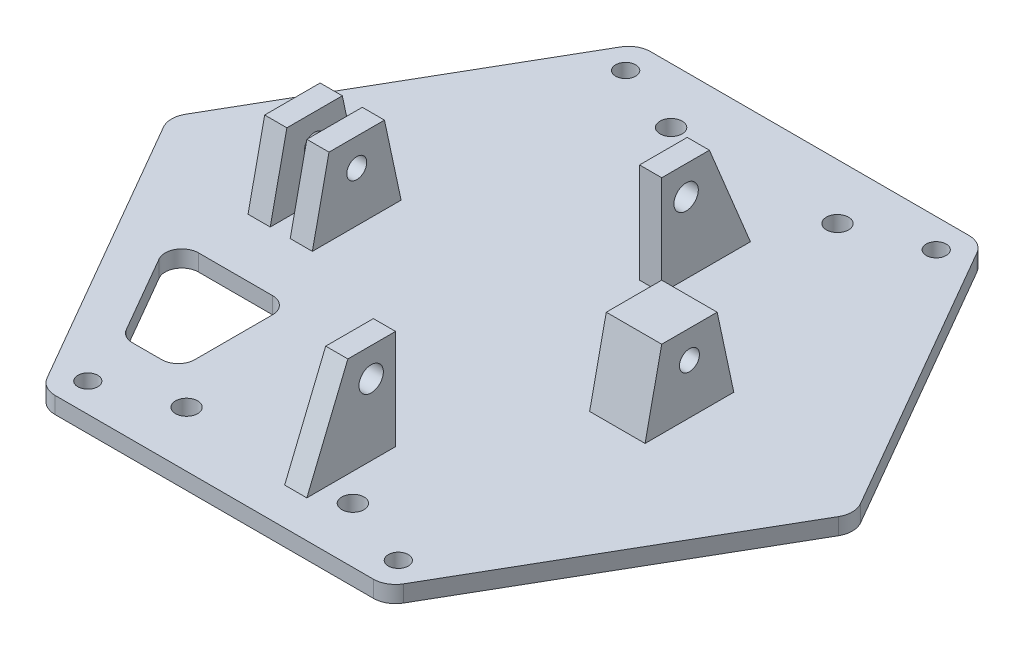
from build123d import *

# Parameters (mm, degrees)
EXTRUDE_1_DEPTH     = 1.5
SKETCH_3_R          = 0.9
EXTRUDE_2_DEPTH     = 2
SKETCH_4_R          = 0.9
EXTRUDE_3_DEPTH     = 2
SKETCH_5_R          = 1.1
EXTRUDE_4_DEPTH     = 2
FILLET_1_R          = 2
SKETCH_6_R          = 0.9
CUT_EXTRUDE_1_DEPTH = 10
SKETCH_7_R          = 1
CUT_EXTRUDE_2_DEPTH = 10
SKETCH_8_R          = 0.9
EXTRUDE_5_DEPTH     = 3
CUT_EXTRUDE_3_DEPTH = 3


with BuildPart() as part:
    # 草图1 → 凸台-拉伸1 (new body)
    with BuildSketch(Plane(origin=(0, 0, 0), x_dir=(1, 0, 0), z_dir=(0, 1, 0))):
        Polygon((15.5, 26.846787517), (-15.5, 26.846787517), (-31, 0), (-15.5, -26.846787517), (15.5, -26.846787517), (31, 0), align=None)
    extrude(amount=EXTRUDE_1_DEPTH)

    # 草图3 → 凸台-拉伸2 (add)
    with BuildSketch(Plane(origin=(16, 0, 0), x_dir=(0, 0, -1), z_dir=(1, 0, 0))):
        Polygon((-4, 1.5), (-2.5, 8.5), (2.5, 8.5), (4, 1.5), align=None)
        with Locations((0, 6)):
            Circle(SKETCH_3_R, mode=Mode.SUBTRACT)
    extrude_2 = extrude(amount=-EXTRUDE_2_DEPTH)

    # 草图4 → 凸台-拉伸3 (add)
    with BuildSketch(Plane(origin=(17.8, 0, 0), x_dir=(0, 0, -1), z_dir=(1, 0, 0))):
        Polygon((-4, 1.5), (4, 1.5), (2.5, 8.5), (-2.5, 8.5), align=None)
        with Locations((0, 6)):
            Circle(SKETCH_4_R, mode=Mode.SUBTRACT)
    extrude_3 = extrude(amount=EXTRUDE_3_DEPTH)

    # 镜向3: 凸台-拉伸2, 凸台-拉伸3 across plane
    add(extrude_2.mirror(Plane(origin=(0, 0, 0), x_dir=(0, 0, 1), z_dir=(1, 0, 0))))
    add(extrude_3.mirror(Plane(origin=(0, 0, 0), x_dir=(0, 0, 1), z_dir=(1, 0, 0))))

    # 草图5 → 凸台-拉伸4 (add)
    with BuildSketch(Plane(origin=(5, 0, 0), x_dir=(0, 0, -1), z_dir=(1, 0, 0))):
        Polygon((-19.8, 10.5), (-15.5, 10.5), (-15.5, 1.5), (-23.5, 1.5), align=None)
        with Locations((-17.7, 7.9)):
            Circle(SKETCH_5_R, mode=Mode.SUBTRACT)
        Polygon((8.5, 10.5), (8.5, 1.5), (16.5, 1.5), (12.8, 10.5), align=None)
        with Locations(Location((10.7, 7.9, 0), (0, 0, 180))):  # turned: the seam where the file's is
            Circle(SKETCH_5_R, mode=Mode.SUBTRACT)
    extrude(amount=-EXTRUDE_4_DEPTH)

    # 圆角1
    fillet_1_edges = [part.edges().sort_by_distance(p)[0] for p in [
        (31, 0.75, 0),
        (15.5, 0.75, 26.846787517),
        (-15.5, 0.75, 26.846787517),
        (-31, 0.75, 0),
        (-15.5, 0.75, -26.846787517),
        (15.5, 0.75, -26.846787517),
    ]]
    fillet(fillet_1_edges, radius=FILLET_1_R)

    # 草图6 → 切除-拉伸1 (cut)
    with BuildSketch(Plane.XZ):
        with Locations(Location((-14, 24.25, 0), (0, 0, 270))):  # turned: the seam where the file's is
            Circle(SKETCH_6_R)
        with Locations(Location((14, 24.25, 0), (0, 0, 90))):  # turned: the seam where the file's is
            Circle(SKETCH_6_R)
        with Locations(Location((14, -24.25, 0), (0, 0, 270))):  # turned: the seam where the file's is
            Circle(SKETCH_6_R)
        with Locations(Location((-14, -24.25, 0), (0, 0, 90))):  # turned: the seam where the file's is
            Circle(SKETCH_6_R)
        with BuildLine():
            Line((-14.97853003, 19.25), (-12.344555434, 19.25))
            ThreePointArc((-12.344555434, 19.25), (-11.283895262, 18.810660172), (-10.844555434, 17.75))
            Line((-10.844555434, 17.75), (-10.844555434, 10.75))
            ThreePointArc((-10.844555434, 10.75), (-11.283895262, 9.689339828), (-12.344555434, 9.25))
            Line((-12.344555434, 9.25), (-19.019981914, 9.25))
            ThreePointArc((-19.019981914, 9.25), (-20.31902002, 10), (-20.31902002, 11.5))
            Line((-20.31902002, 11.5), (-16.277568136, 18.5))
            ThreePointArc((-16.277568136, 18.5), (-15.72853003, 19.049038106), (-14.97853003, 19.25))
        make_face()
    extrude(amount=-CUT_EXTRUDE_1_DEPTH, mode=Mode.SUBTRACT)

    # 草图7 → 切除-拉伸2 (cut)
    with BuildSketch(Plane.XZ):
        with Locations(Location((-7.5, -21.846787517, 0), (0, 0, 270))):  # turned: the seam where the file's is
            Circle(SKETCH_7_R)
        with Locations(Location((7.5, -21.846787517, 0), (0, 0, 90))):  # turned: the seam where the file's is
            Circle(SKETCH_7_R)
        with Locations(Location((7.5, 21.846787517, 0), (0, 0, 270))):  # turned: the seam where the file's is
            Circle(SKETCH_7_R)
        with Locations(Location((-7.5, 21.846787517, 0), (0, 0, 90))):  # turned: the seam where the file's is
            Circle(SKETCH_7_R)
    extrude(amount=-CUT_EXTRUDE_2_DEPTH, mode=Mode.SUBTRACT)

    # 草图8 → 凸台-拉伸5 (add)
    with BuildSketch(Plane.ZY.offset(-14)):
        Polygon((-4, 1.5), (4, 1.5), (2.5, 8.5), (-2.5, 8.5), align=None)
        with Locations(Location((0, 6, 0), (0, 0, 180))):  # turned: the seam where the file's is
            Circle(SKETCH_8_R, mode=Mode.SUBTRACT)
    extrude(amount=EXTRUDE_5_DEPTH)

    # 草图9 → 切除-拉伸3 (cut)
    with BuildSketch(Plane(origin=(19.8, 0, 0), x_dir=(0, 0, -1), z_dir=(1, 0, 0))):
        Polygon((-2.5, 8.5), (-4, 1.5), (4, 1.5), (2.5, 8.5), align=None)
    extrude(amount=-CUT_EXTRUDE_3_DEPTH, mode=Mode.SUBTRACT)


solid = part.part
